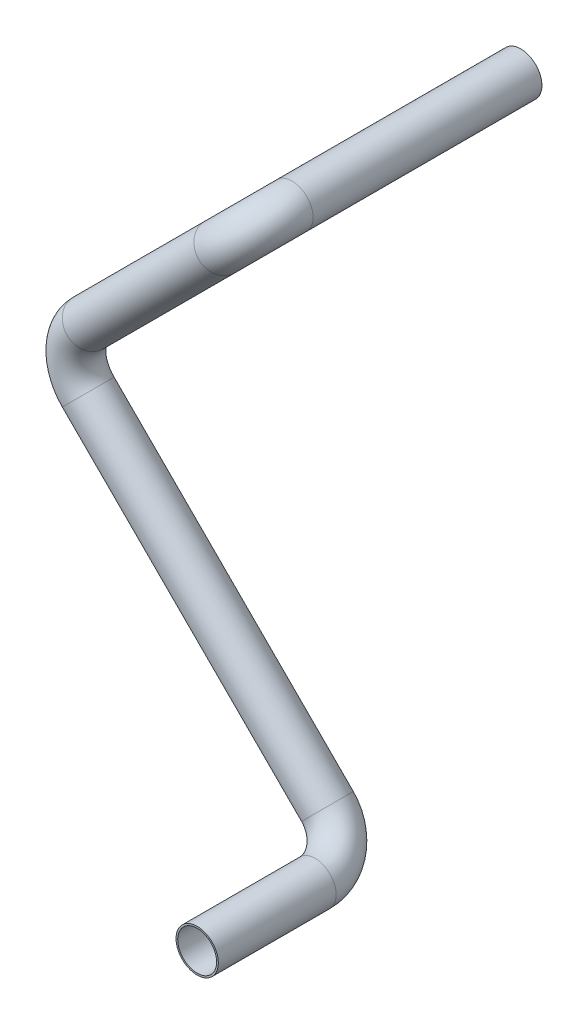
from build123d import *

# Parameters (mm, degrees)
PIPESKETCH_R   = 6.35
PIPESKETCH_R_2 = 5.842


with BuildPart() as part:
    # ThinSweep: sweep along a curve in space
    with BuildLine() as thinsweep_path:
        Line((0, 0, 0), (0, 0, 68.7121))
        ThreePointArc((0, 0, 68.7121), (-2.630256121, -2.630256121, 77.692356121), (-8.980256121, -8.980256121, 81.4121))
        Line((-8.980256121, -8.980256121, 81.4121), (-48.493383054, -48.493383054, 81.4121))
        ThreePointArc((-48.493383054, -48.493383054, 81.4121), (-52.213126933, -57.473639175, 81.4121), (-48.493383054, -66.453895296, 81.4121))
        Line((-48.493383054, -66.453895296, 81.4121), (23.348665915, -138.295944264, 81.4121))
        ThreePointArc((23.348665915, -138.295944264, 81.4121), (29.698665915, -144.645944264, 85.131843879), (32.328922036, -147.276200386, 94.1121))
        Line((32.328922036, -147.276200386, 129.5121), (32.328922036, -147.276200386, 94.1121))
    # PipeSketch → ThinSweep (sweep)
    with BuildSketch(Plane.XY):
        Circle(PIPESKETCH_R)
        Circle(PIPESKETCH_R_2, mode=Mode.SUBTRACT)
    sweep(path=thinsweep_path.line)


solid = part.part
